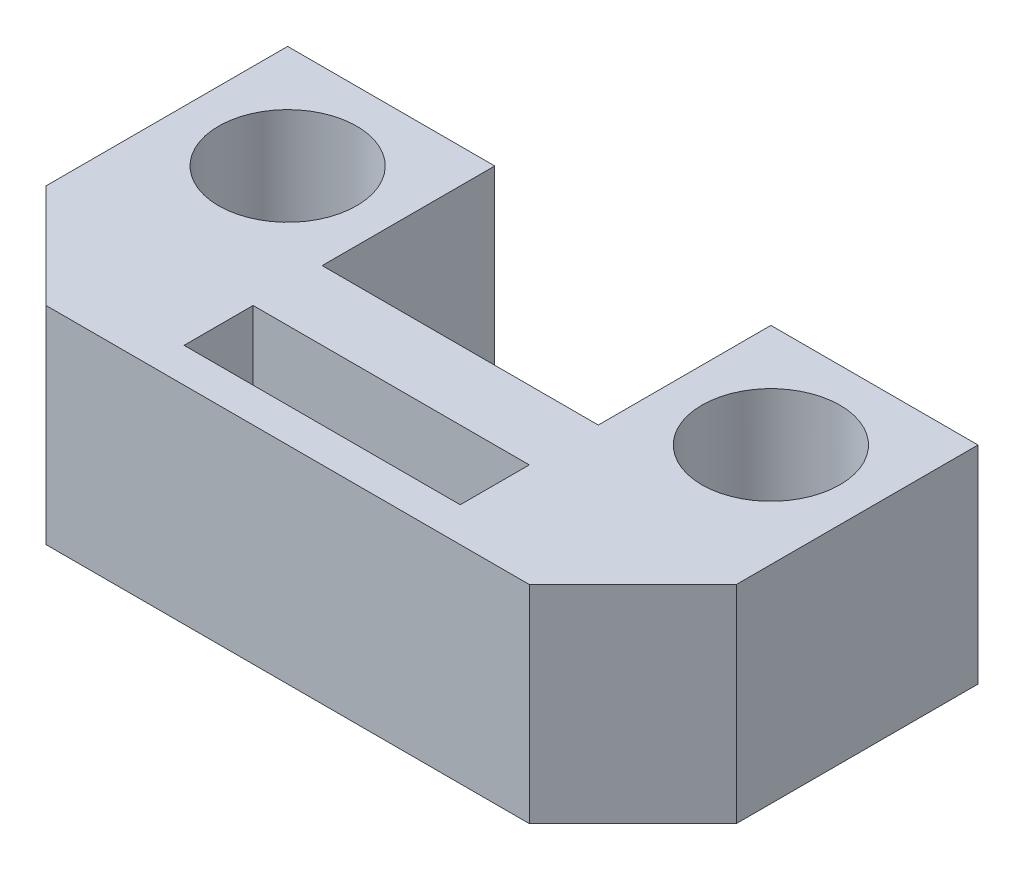
from build123d import *

# Parameters (mm, degrees)
EXTRUDE_1_DEPTH     = 6
CUT_EXTRUDE_3_REACH = 8
SKETCH_2_R          = 2
SKETCH_2_W          = 8
SKETCH_2_H          = 2
CHAMFER_1_SIZE      = 3


with BuildPart() as part:
    # 草图1 → 凸台-拉伸1 (new body)
    with BuildSketch(Plane(origin=(0, 0, 0), x_dir=(1, 0, 0), z_dir=(0, 1, 0))):
        Polygon((-4, 5), (-4, 10), (-10, 10), (-10, 5), (-10, 0), (10, 0), (10, 5), (10, 10), (4, 10), (4, 5), align=None)
    extrude(amount=EXTRUDE_1_DEPTH)

    # 草图2 → 切除-拉伸3 (cut, up to next)
    with BuildSketch(Plane(origin=(0, 6, 0), x_dir=(1, 0, 0), z_dir=(0, 1, 0)), mode=Mode.PRIVATE) as cut_extrude_3_sk1:
        with Locations((-7, 7)):
            Circle(SKETCH_2_R)
    cut_extrude_3_tool1 = extrude(cut_extrude_3_sk1.sketch, amount=-CUT_EXTRUDE_3_REACH, mode=Mode.PRIVATE) & part.part
    add(cut_extrude_3_tool1.solids().sort_by_distance((-7, 6, -7))[0], mode=Mode.SUBTRACT)
    # 草图2 → 切除-拉伸3 (cut, up to next)
    with BuildSketch(Plane(origin=(0, 6, 0), x_dir=(1, 0, 0), z_dir=(0, 1, 0)), mode=Mode.PRIVATE) as cut_extrude_3_sk2:
        with Locations((7, 7)):
            Circle(SKETCH_2_R)
    cut_extrude_3_tool2 = extrude(cut_extrude_3_sk2.sketch, amount=-CUT_EXTRUDE_3_REACH, mode=Mode.PRIVATE) & part.part
    add(cut_extrude_3_tool2.solids().sort_by_distance((7, 6, -7))[0], mode=Mode.SUBTRACT)
    # 草图2 → 切除-拉伸3 (cut, up to next)
    with BuildSketch(Plane(origin=(0, 6, 0), x_dir=(1, 0, 0), z_dir=(0, 1, 0)), mode=Mode.PRIVATE) as cut_extrude_3_sk3:
        with Locations((0, 2)):
            Rectangle(SKETCH_2_W, SKETCH_2_H)
    cut_extrude_3_tool3 = extrude(cut_extrude_3_sk3.sketch, amount=-CUT_EXTRUDE_3_REACH, mode=Mode.PRIVATE) & part.part
    add(cut_extrude_3_tool3.solids().sort_by_distance((0, 6, -2))[0], mode=Mode.SUBTRACT)

    # 倒角1
    chamfer_1_edges = [part.edges().sort_by_distance(p)[0] for p in [
        (10, 3, 0),
        (-10, 3, 0),
    ]]
    chamfer(chamfer_1_edges, length=CHAMFER_1_SIZE)


solid = part.part
